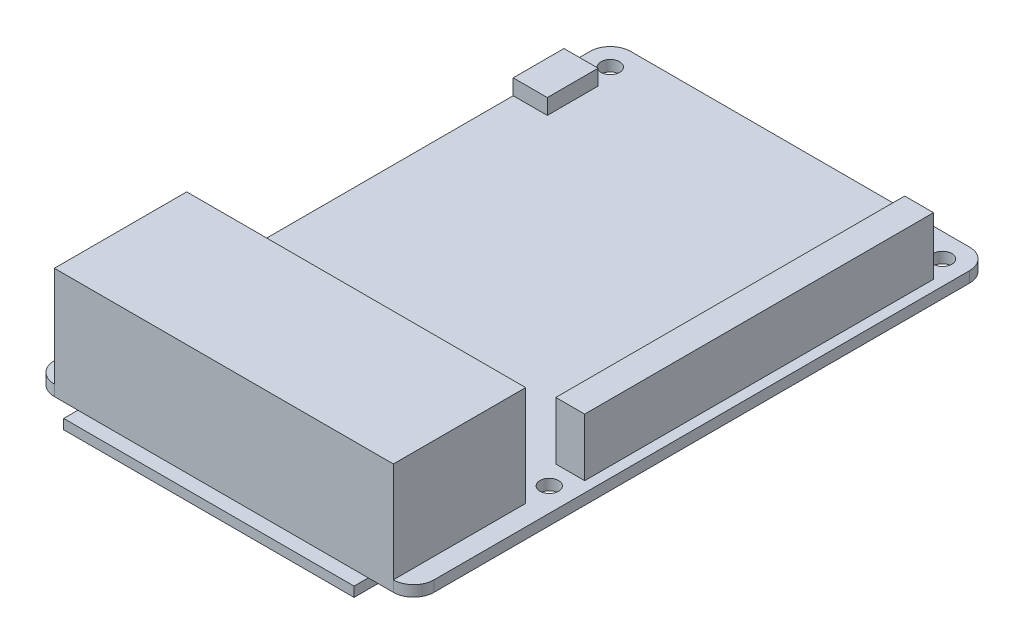
from build123d import *

# Parameters (mm, degrees)
BOSS_EXTRUDE1_DEPTH        = 1.6002
F_2_7_2_7_DIAMETER_HOLE1_D = 2.75
SKETCH4_W                  = 50
SKETCH4_H                  = 19.517145321
BOSS_EXTRUDE2_DEPTH        = 14.8
SKETCH5_W                  = 42.835025658
SKETCH5_H                  = 82.243586595
BOSS_EXTRUDE3_DEPTH        = 1.4478
SKETCH6_W                  = 5.032927575
SKETCH6_H                  = 7.493
BOSS_EXTRUDE4_DEPTH        = 2.286
SKETCH7_W                  = 4.25671985
SKETCH7_H                  = 51.456231134
BOSS_EXTRUDE5_DEPTH        = 8.509


with BuildPart() as part:
    # Sketch1 → Boss-Extrude1 (new body)
    with BuildSketch(Plane(origin=(0, 0, 0), x_dir=(1, 0, 0), z_dir=(0, 1, 0))):
        with BuildLine():
            Line((3, 0), (53, 0))
            ThreePointArc((53, 0), (55.121320344, 0.878679656), (56, 3))
            Line((56, 3), (56, 82))
            ThreePointArc((56, 82), (55.121320344, 84.121320344), (53, 85))
            Line((53, 85), (3, 85))
            ThreePointArc((3, 85), (0.878679656, 84.121320344), (0, 82))
            Line((0, 82), (0, 3))
            ThreePointArc((0, 3), (0.878679656, 0.878679656), (3, 0))
        make_face()
    extrude(amount=BOSS_EXTRUDE1_DEPTH)

    # Ø2.7 (2.7) Diameter Hole1 (through all)
    with Locations(Plane(origin=(0, 1.6002, 0), x_dir=(1, 0, 0), z_dir=(0, 1, 0))):
        with Locations((3.5, 81.5), (3.5, 23.5), (52.5, 81.5), (52.5, 23.5)):
            Hole(F_2_7_2_7_DIAMETER_HOLE1_D / 2)

    # Sketch4 → Boss-Extrude2 (add)
    with BuildSketch(Plane(origin=(0, 1.6002, 0), x_dir=(1, 0, 0), z_dir=(0, 1, 0))):
        with Locations((28, 9.758572661)):
            Rectangle(SKETCH4_W, SKETCH4_H)
    extrude(amount=BOSS_EXTRUDE2_DEPTH)

    # Sketch5 → Boss-Extrude3 (add)
    with BuildSketch(Plane.XZ):
        with Locations((27.885782236, -39.021793298)):
            Rectangle(SKETCH5_W, SKETCH5_H)
    extrude(amount=BOSS_EXTRUDE3_DEPTH)

    # Sketch7 → Boss-Extrude5 (add)
    with BuildSketch(Plane(origin=(0, 1.6002, 0), x_dir=(1, 0, 0), z_dir=(0, 1, 0))):
        with Locations((52.319642087, 52.498691965)):
            Rectangle(SKETCH7_W, SKETCH7_H)
    extrude(amount=BOSS_EXTRUDE5_DEPTH)


with BuildPart() as body_2:
    # Sketch6 → Boss-Extrude4 (new body)
    with BuildSketch(Plane(origin=(0, 1.6002, 0), x_dir=(1, 0, 0), z_dir=(0, 1, 0))):
        with Locations((2.516463788, 74.4209)):
            Rectangle(SKETCH6_W, SKETCH6_H)
    extrude(amount=BOSS_EXTRUDE4_DEPTH)


solid = Compound([part.part, body_2.part])
